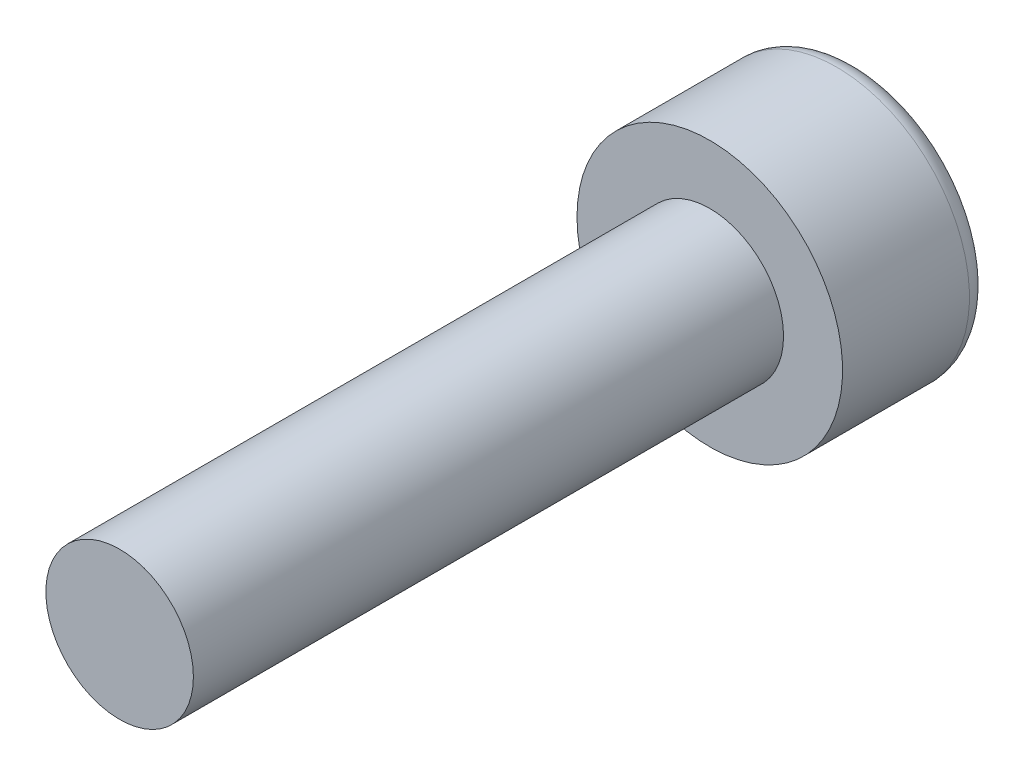
from build123d import *

# Parameters (mm, degrees)
CROQUIS1_R              = 1.25
SALIENTE_EXTRUIR1_DEPTH = 10
CROQUIS2_R              = 2.25
SALIENTE_EXTRUIR2_DEPTH = 2.5
CORTAR_EXTRUIR1_DEPTH   = 1.5
REDONDEO1_R             = 0.35


with BuildPart() as part:
    # Croquis1 → Saliente-Extruir1 (new body)
    with BuildSketch(Plane.XY):
        Circle(CROQUIS1_R)
    extrude(amount=SALIENTE_EXTRUIR1_DEPTH)

    # Croquis2 → Saliente-Extruir2 (add)
    with BuildSketch(Plane(origin=(0, 0, 0), x_dir=(-1, 0, 0), z_dir=(0, 0, -1))):
        Circle(CROQUIS2_R)
    extrude(amount=SALIENTE_EXTRUIR2_DEPTH)

    # Croquis3 → Cortar-Extruir1 (cut)
    with BuildSketch(Plane(origin=(0, 0, -2.5), x_dir=(-1, 0, 0), z_dir=(0, 0, -1))):
        Polygon((0, -1.154700538), (1, -0.577350269), (1, 0.577350269), (0, 1.154700538), (-1, 0.577350269), (-1, -0.577350269), align=None)
    extrude(amount=-CORTAR_EXTRUIR1_DEPTH, mode=Mode.SUBTRACT)

    # Redondeo1
    redondeo1_edges = [part.edges().sort_by_distance(p)[0] for p in [
        (2.25, 0, -2.5),
    ]]
    fillet(redondeo1_edges, radius=REDONDEO1_R)


solid = part.part
